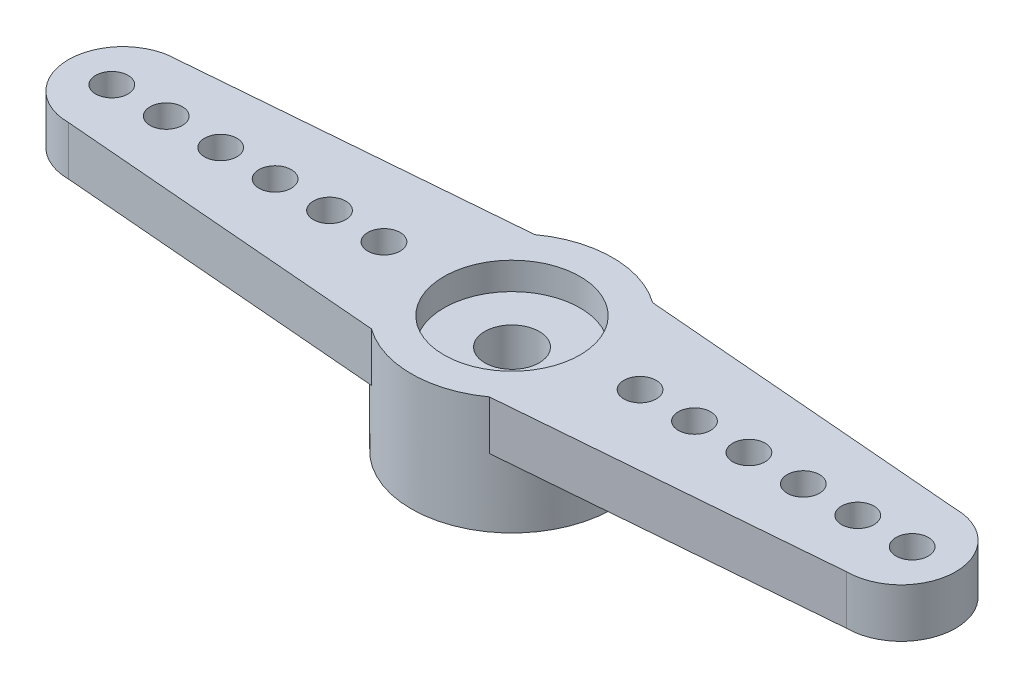
from build123d import *

# Parameters (mm, degrees)
CROQUIS1_R              = 3.7
SALIENTE_EXTRUIR2_DEPTH = 4.3
CROQUIS2_R              = 2.5
CORTAR_EXTRUIR1_DEPTH   = 1.5
CROQUIS3_R              = 2.5
CORTAR_EXTRUIR2_DEPTH   = 1
CROQUIS4_R              = 1
CORTAR_EXTRUIR3_DEPTH   = 1.8
SALIENTE_EXTRUIR3_DEPTH = 1.8
CROQUIS6_R              = 0.595
CORTAR_EXTRUIR4_DEPTH   = 1.8


with BuildPart() as part:
    # Croquis1 → Saliente-Extruir2 (new body)
    with BuildSketch(Plane(origin=(0, 0, 0), x_dir=(1, 0, 0), z_dir=(0, 1, 0))):
        Circle(CROQUIS1_R)
    extrude(amount=SALIENTE_EXTRUIR2_DEPTH)

    # Croquis2 → Cortar-Extruir1 (cut)
    with BuildSketch(Plane.XZ):
        Circle(CROQUIS2_R)
    extrude(amount=-CORTAR_EXTRUIR1_DEPTH, mode=Mode.SUBTRACT)

    # Croquis3 → Cortar-Extruir2 (cut)
    with BuildSketch(Plane(origin=(0, 4.3, 0), x_dir=(1, 0, 0), z_dir=(0, 1, 0))):
        Circle(CROQUIS3_R)
    extrude(amount=-CORTAR_EXTRUIR2_DEPTH, mode=Mode.SUBTRACT)

    # Croquis4 → Cortar-Extruir3 (cut)
    with BuildSketch(Plane(origin=(0, 3.3, 0), x_dir=(1, 0, 0), z_dir=(0, 1, 0))):
        Circle(CROQUIS4_R)
    extrude(amount=-CORTAR_EXTRUIR3_DEPTH, mode=Mode.SUBTRACT)

    # Croquis5 → Saliente-Extruir3 (add)
    with BuildSketch(Plane(origin=(0, 4.3, 0), x_dir=(1, 0, 0), z_dir=(0, 1, 0))):
        with BuildLine():
            Line((-2.16564, 3.000000565), (-3.120237459, 0))
            Line((-3.120237459, 0), (-2.16564, -3.000000565))
            Line((-2.16564, -3.000000565), (-14.3, -2))
            ThreePointArc((-14.3, -2), (-16.3, 0), (-14.3, 2))
            Line((-14.3, 2), (-2.16564, 3.000000565))
        make_face()
        with BuildLine():
            Line((3.120237459, 0), (2.16564, -3.000000565))
            Line((2.16564, -3.000000565), (14.3, -2))
            ThreePointArc((14.3, -2), (16.3, 0), (14.3, 2))
            Line((14.3, 2), (2.16564, 3.000000565))
            Line((2.16564, 3.000000565), (3.120237459, 0))
        make_face()
    extrude(amount=-SALIENTE_EXTRUIR3_DEPTH)

    # Croquis6 → Cortar-Extruir4 (cut)
    with BuildSketch(Plane(origin=(0, 4.3, 0), x_dir=(1, 0, 0), z_dir=(0, 1, 0))):
        with Locations((-14.705, 0)):
            Circle(CROQUIS6_R)
        with Locations((-12.705, 0)):
            Circle(CROQUIS6_R)
        with Locations((-10.705, 0)):
            Circle(CROQUIS6_R)
        with Locations((-8.705, 0)):
            Circle(CROQUIS6_R)
        with Locations((-6.705, 0)):
            Circle(CROQUIS6_R)
        with Locations((-4.705, 0)):
            Circle(CROQUIS6_R)
        with Locations((14.705, 0)):
            Circle(CROQUIS6_R)
        with Locations((12.705, 0)):
            Circle(CROQUIS6_R)
        with Locations((10.705, 0)):
            Circle(CROQUIS6_R)
        with Locations((8.705, 0)):
            Circle(CROQUIS6_R)
        with Locations((6.705, 0)):
            Circle(CROQUIS6_R)
        with Locations((4.705, 0)):
            Circle(CROQUIS6_R)
    extrude(amount=-CORTAR_EXTRUIR4_DEPTH, mode=Mode.SUBTRACT)


solid = part.part
